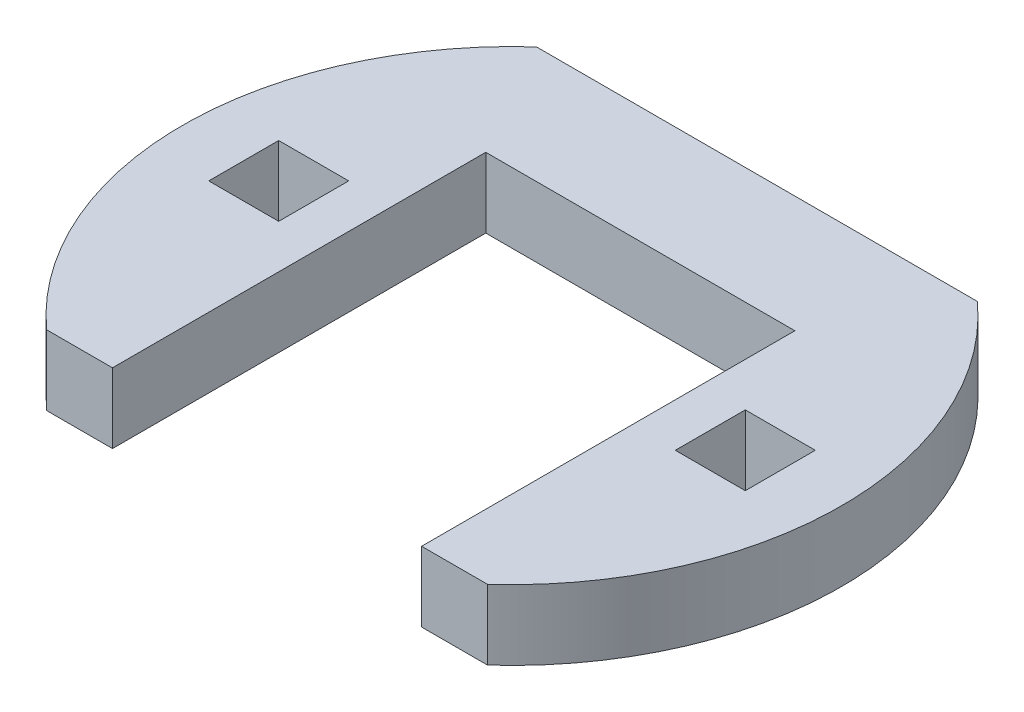
from build123d import *

# Parameters (mm, degrees)
SALIENTE_EXTRUIR1_DEPTH = 6
CROQUIS7_R              = 40
SALIENTE_EXTRUIR5_DEPTH = 6
SALIENTE_EXTRUIR3_DEPTH = 6
CROQUIS6_R              = 1.75
SALIENTE_EXTRUIR4_DEPTH = 6
CROQUIS8_W              = 6
CROQUIS8_H              = 6
CORTAR_EXTRUIR1_DEPTH   = 25
CROQUIS9_W              = 322
CROQUIS9_H              = 247
CORTAR_EXTRUIR2_DEPTH   = 12
CROQUIS10_R             = 28.25
CORTAR_EXTRUIR3_DEPTH   = 6


with BuildPart() as part:
    # Croquis1 → Saliente-Extruir1 (new body)
    with BuildSketch(Plane(origin=(0, 0, 0), x_dir=(1, 0, 0), z_dir=(0, 1, 0))):
        with BuildLine():
            Line((-161, 103.5), (-38.791887254, 9.756509788))
            ThreePointArc((-38.791887254, 9.756509788), (-40, 0), (-38.791887254, -9.756509788))
            Line((-38.791887254, -9.756509788), (-161, -103.5))
            Line((-161, -103.5), (-161, -123.5))
            Line((-161, -123.5), (-141, -123.5))
            Line((-141, -123.5), (-22.823766962, -32.84928708))
            ThreePointArc((-22.823766962, -32.84928708), (0, -40), (22.823766962, -32.84928708))
            Line((22.823766962, -32.84928708), (141, -123.5))
            Line((141, -123.5), (161, -123.5))
            Line((161, -123.5), (161, -103.5))
            Line((161, -103.5), (38.791887254, -9.756509788))
            ThreePointArc((38.791887254, -9.756509788), (40, 0), (38.791887254, 9.756509788))
            Line((38.791887254, 9.756509788), (161, 103.5))
            Line((161, 103.5), (161, 123.5))
            Line((161, 123.5), (141, 123.5))
            Line((141, 123.5), (22.823766962, 32.84928708))
            ThreePointArc((22.823766962, 32.84928708), (0, 40), (-22.823766962, 32.84928708))
            Line((-22.823766962, 32.84928708), (-141, 123.5))
            Line((-141, 123.5), (-161, 123.5))
            Line((-161, 123.5), (-161, 103.5))
        make_face()
    extrude(amount=SALIENTE_EXTRUIR1_DEPTH)

    # Croquis7 → Saliente-Extruir5 (add)
    with BuildSketch(Plane(origin=(0, 0, 0), x_dir=(-1, 0, 0), z_dir=(0, -1, 0))):
        Circle(CROQUIS7_R)
    extrude(amount=SALIENTE_EXTRUIR5_DEPTH)

    # Croquis5 → Saliente-Extruir3 (add)
    with BuildSketch(Plane.XZ.offset(6)):
        with BuildLine():
            Line((18.896097481, -21), (-18.896097481, -21))
            ThreePointArc((-18.896097481, -21), (-28.25, 0), (-18.896097481, 21))
            Line((-18.896097481, 21), (-13.25, 21))
            Line((-13.25, 21), (-13.25, -11))
            Line((-13.25, -11), (13.25, -11))
            Line((13.25, -11), (13.25, 21))
            Line((13.25, 21), (18.896097481, 21))
            ThreePointArc((18.896097481, 21), (28.25, 0), (18.896097481, -21))
        make_face()
    extrude(amount=SALIENTE_EXTRUIR3_DEPTH)

    # Croquis6 → Saliente-Extruir4 (add)
    with BuildSketch(Plane.XZ.offset(12)):
        with BuildLine():
            Line((-18.896097481, 21), (-13.25, 21))
            Line((-13.25, 21), (-13.25, 3.5))
            ThreePointArc((-13.25, 3.5), (-13.103553391, 3.146446609), (-12.75, 3))
            Line((-12.75, 3), (12.75, 3))
            ThreePointArc((12.75, 3), (13.103553391, 3.146446609), (13.25, 3.5))
            Line((13.25, 3.5), (13.25, 21))
            Line((13.25, 21), (18.896097481, 21))
            ThreePointArc((18.896097481, 21), (28.25, 0), (18.896097481, -21))
            Line((18.896097481, -21), (-18.896097481, -21))
            ThreePointArc((-18.896097481, -21), (-28.25, 0), (-18.896097481, 21))
        make_face()
        with Locations((-8, -5.75)):
            Circle(CROQUIS6_R, mode=Mode.SUBTRACT)
        with Locations((8, -5.75)):
            Circle(CROQUIS6_R, mode=Mode.SUBTRACT)
    extrude(amount=SALIENTE_EXTRUIR4_DEPTH)

    # Croquis8 → Cortar-Extruir1 (cut, through all)
    with BuildSketch(Plane.XZ.offset(18)):
        with Locations((-20, 0)):
            Rectangle(CROQUIS8_W, CROQUIS8_H)
        with Locations((20, 0)):
            Rectangle(CROQUIS8_W, CROQUIS8_H)
    extrude(amount=-CORTAR_EXTRUIR1_DEPTH, mode=Mode.SUBTRACT)

    # Croquis9 → Cortar-Extruir2 (cut)
    with BuildSketch(Plane(origin=(0, 6, 0), x_dir=(1, 0, 0), z_dir=(0, 1, 0))):
        Rectangle(CROQUIS9_W, CROQUIS9_H)
    extrude(amount=-CORTAR_EXTRUIR2_DEPTH, mode=Mode.SUBTRACT)

    # Croquis10 → Cortar-Extruir3 (cut)
    with BuildSketch(Plane(origin=(0, -18, 0), x_dir=(1, 0, 0), z_dir=(0, 1, 0))):
        Circle(CROQUIS10_R)
    extrude(amount=CORTAR_EXTRUIR3_DEPTH, mode=Mode.SUBTRACT)


solid = part.part
